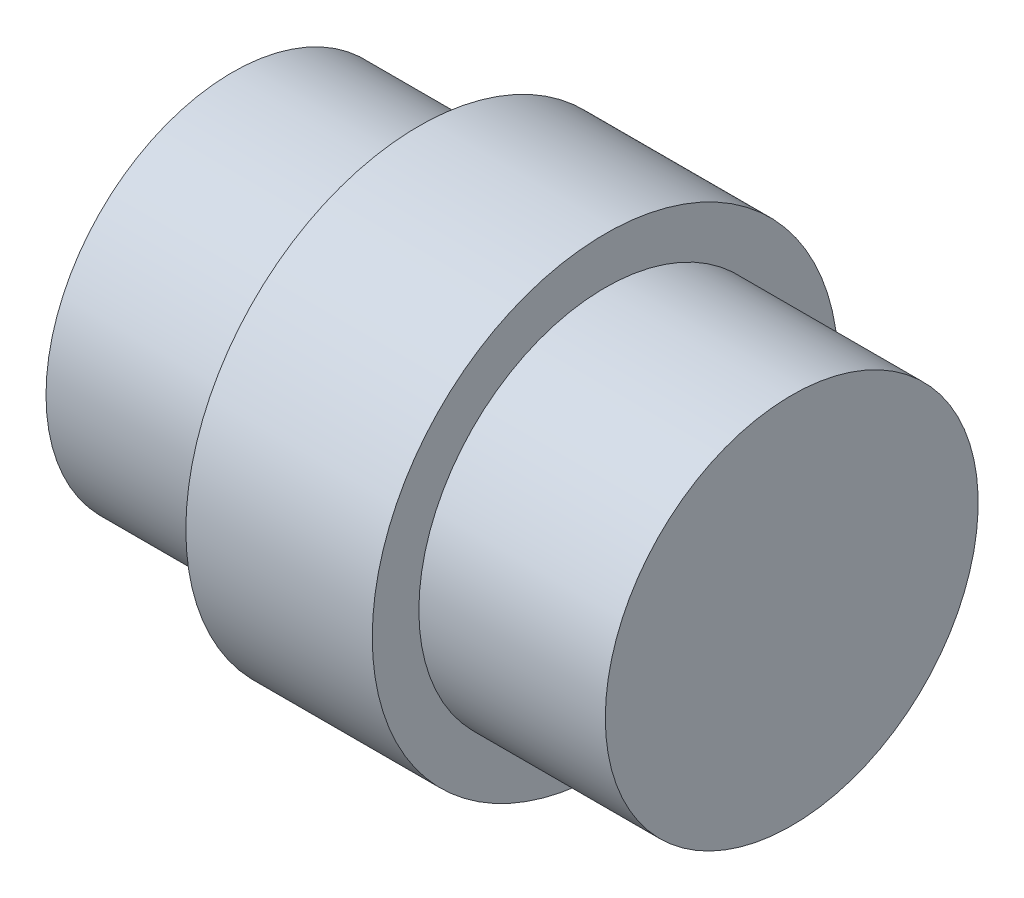
from build123d import *

# Parameters (mm, degrees)
SKETCH1_R           = 12.5
BOSS_EXTRUDE1_DEPTH = 15
SKETCH2_R           = 12.5
SKETCH2_R_2         = 10
CUT_EXTRUDE1_DEPTH  = 10


with BuildPart() as part:
    # Sketch1 → Boss-Extrude1 (new body, symmetric)
    with BuildSketch(Plane(origin=(0, 0, 0), x_dir=(0, 0, -1), z_dir=(1, 0, 0))):
        Circle(SKETCH1_R)
    extrude(amount=BOSS_EXTRUDE1_DEPTH, both=True)

    # Sketch2 → Cut-Extrude1 (cut)
    with BuildSketch(Plane.ZY.offset(15)):
        Circle(SKETCH2_R)
        Circle(SKETCH2_R_2, mode=Mode.SUBTRACT)
    cut_extrude1 = extrude(amount=-CUT_EXTRUDE1_DEPTH, mode=Mode.SUBTRACT)

    # Mirror1: Cut-Extrude1 across plane
    add(cut_extrude1.mirror(Plane(origin=(0, 0, 0), x_dir=(0, 0, 1), z_dir=(1, 0, 0))), mode=Mode.SUBTRACT)


solid = part.part
